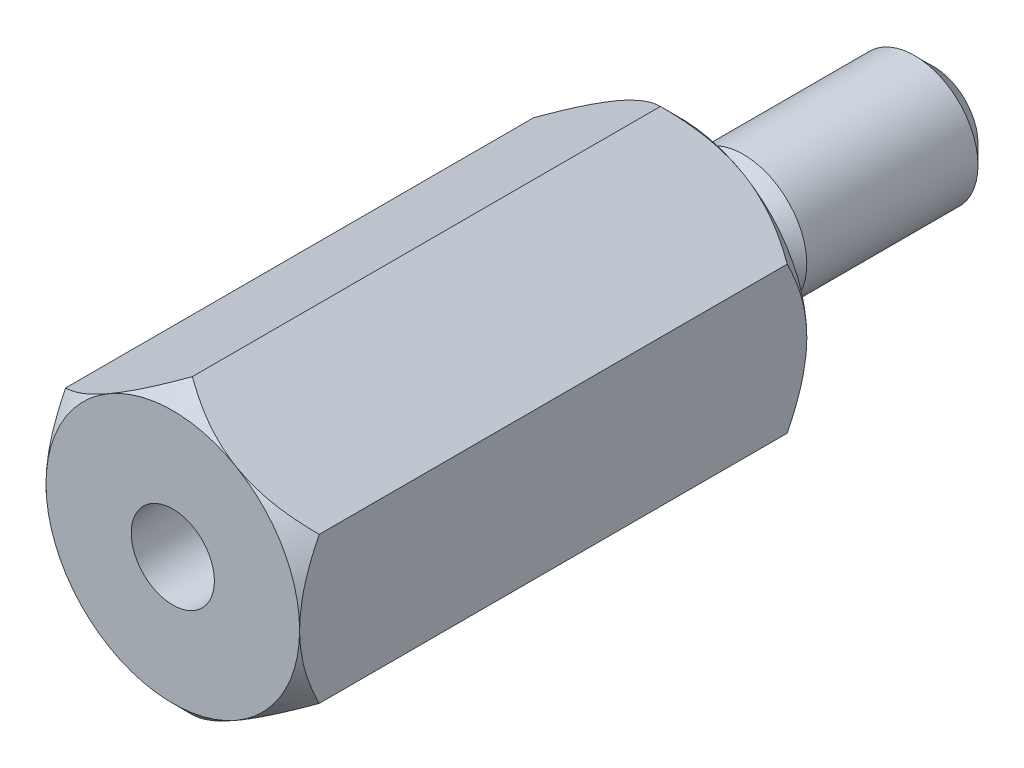
from build123d import *

# Parameters (mm, degrees)
BOSS_EXTRUDE1_START = 19.05
BOSS_EXTRUDE1_DEPTH = 25.4
CHAMFER1_SIZE       = 0.9525
SKETCH4_R           = 2.0828
CUT_EXTRUDE1_DEPTH  = 11.1125
FILLET1_R           = 0.09921875
SKETCH5_OUTSIDE_W   = 101.45
SKETCH5_OUTSIDE_H   = 103.414
SKETCH5_OUTSIDE_R   = 6.35
CUT_EXTRUDE2_DEPTH  = 39.1
CUT_EXTRUDE2_TAPER  = 45
SKETCH6_OUTSIDE_W   = 76.05
SKETCH6_OUTSIDE_H   = 78.014
SKETCH6_OUTSIDE_R   = 6.35
CUT_EXTRUDE3_DEPTH  = 26.4
CUT_EXTRUDE3_TAPER  = 45


with BuildPart() as part:
    # Sketch2 → Boss-Extrude1 (new body)
    with BuildSketch(Plane.XY.offset(BOSS_EXTRUDE1_START)):
        Polygon((6.35, 3.666174209), (0, 7.332348419), (-6.35, 3.666174209), (-6.35, -3.666174209), (0, -7.332348419), (6.35, -3.666174209), align=None)
    extrude(amount=-BOSS_EXTRUDE1_DEPTH)

    # Sketch3 → Revolve1 (revolve)
    with BuildSketch(Plane(origin=(0, 0, 0), x_dir=(0, 0, -1), z_dir=(1, 0, 0))):
        Polygon((6.35, 2.2225), (8.5725, 2.2225), (9.525, 3.175), (19.05, 3.175), (19.05, 0), (6.35, 0), align=None)
    revolve(axis=Axis((0, 0, 19.05), (0, 0, -1)))

    # Chamfer1
    chamfer1_edges = [part.edges().sort_by_distance(p)[0] for p in [
        (0, -3.175, -19.05),
    ]]
    chamfer(chamfer1_edges, length=CHAMFER1_SIZE)

    # Sketch4 → Cut-Extrude1 (cut)
    with BuildSketch(Plane.XY.offset(19.05)):
        Circle(SKETCH4_R)
    extrude(amount=-CUT_EXTRUDE1_DEPTH, mode=Mode.SUBTRACT)

    # Fillet1
    fillet1_edges = [part.edges().sort_by_distance(p)[0] for p in [
        (0, -2.2225, -6.35),
    ]]
    fillet(fillet1_edges, radius=FILLET1_R)

    # Sketch5 outside → Cut-Extrude2 (cut, through all)
    with BuildSketch(Plane.XY.offset(19.05)):
        Rectangle(SKETCH5_OUTSIDE_W, SKETCH5_OUTSIDE_H)
        Circle(SKETCH5_OUTSIDE_R, mode=Mode.SUBTRACT)
    extrude(amount=-CUT_EXTRUDE2_DEPTH, taper=CUT_EXTRUDE2_TAPER, mode=Mode.SUBTRACT)

    # Sketch6 outside → Cut-Extrude3 (cut, through all)
    with BuildSketch(Plane(origin=(0, 0, -6.35), x_dir=(-1, 0, 0), z_dir=(0, 0, -1))):
        Rectangle(SKETCH6_OUTSIDE_W, SKETCH6_OUTSIDE_H)
        Circle(SKETCH6_OUTSIDE_R, mode=Mode.SUBTRACT)
    extrude(amount=-CUT_EXTRUDE3_DEPTH, taper=CUT_EXTRUDE3_TAPER, mode=Mode.SUBTRACT)


solid = part.part
